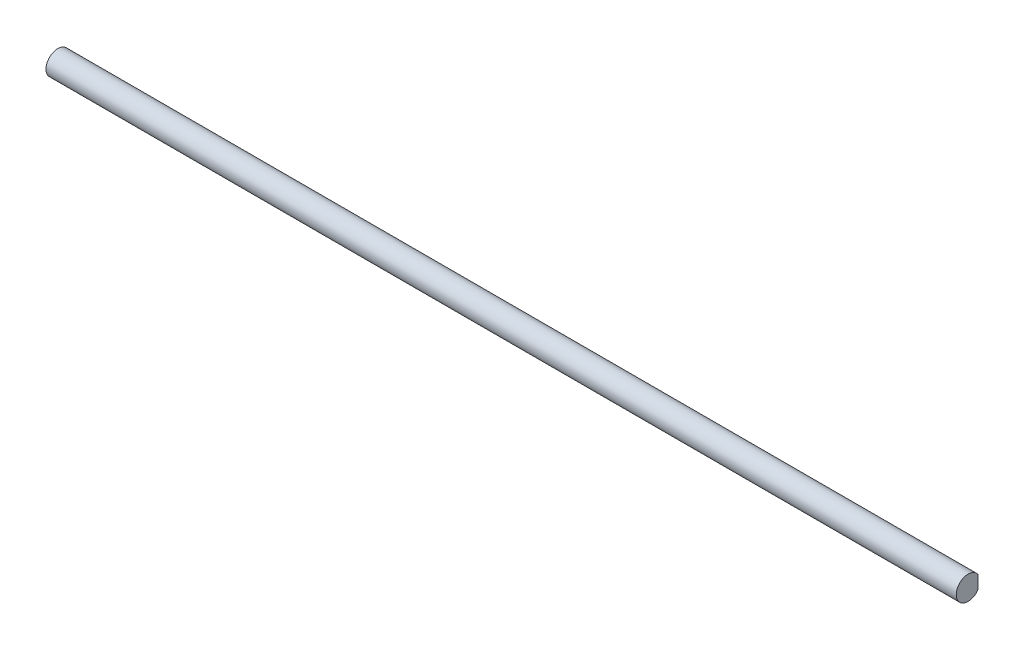
from build123d import *

# Parameters (mm, degrees)
SKETCH_1_R          = 6
EXTRUDE_1_DEPTH     = 460
SKETCH_2_W          = 15.5
SKETCH_2_H          = 1
CUT_EXTRUDE_1_DEPTH = 200


with BuildPart() as part:
    # 草图1 → 凸台-拉伸1 (new body)
    with BuildSketch(Plane(origin=(0, 0, 0), x_dir=(0, 0, -1), z_dir=(1, 0, 0))):
        Circle(SKETCH_1_R)
    extrude(amount=EXTRUDE_1_DEPTH)

    # 草图2 → 切除-拉伸1 (cut, symmetric)
    with BuildSketch(Plane(origin=(0, 0, 0), x_dir=(1, 0, 0), z_dir=(0, 1, 0))):
        with Locations((7.75, 5.5)):
            Rectangle(SKETCH_2_W, SKETCH_2_H)
    cut_extrude_1 = extrude(amount=CUT_EXTRUDE_1_DEPTH, both=True, mode=Mode.SUBTRACT)

    # 镜向1: 切除-拉伸1 across plane
    add(cut_extrude_1.mirror(Plane.ZY.offset(-230)), mode=Mode.SUBTRACT)


solid = part.part
